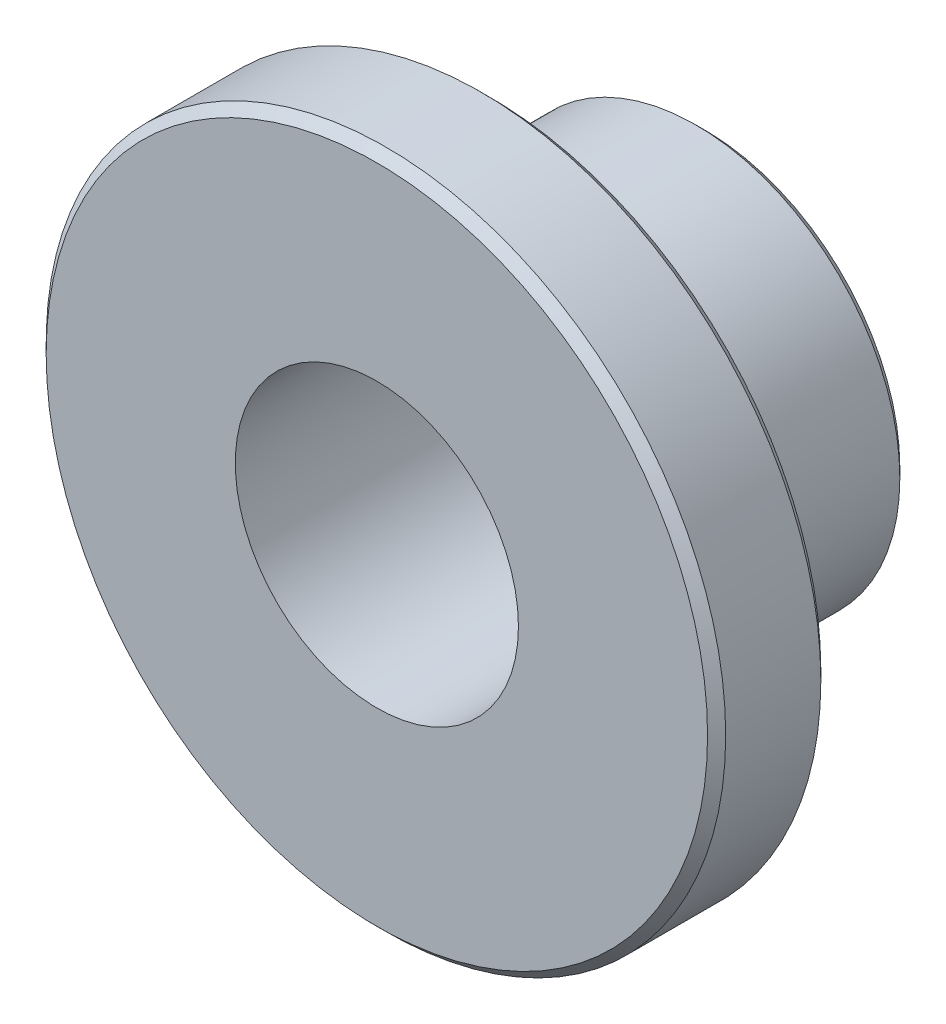
from build123d import *

# Parameters (mm, degrees)
SKETCH1_R           = 5.715
SKETCH1_R_2         = 3.96875
BOSS_EXTRUDE1_DEPTH = 4.6
SKETCH2_R           = 9.525
SKETCH2_R_2         = 5.715
BOSS_EXTRUDE2_DEPTH = 3.175
CHAMFER2_SIZE       = 0.254


with BuildPart() as part:
    # Sketch1 → Boss-Extrude1 (new body, symmetric)
    with BuildSketch(Plane.XY):
        Circle(SKETCH1_R)
        Circle(SKETCH1_R_2, mode=Mode.SUBTRACT)
    extrude(amount=BOSS_EXTRUDE1_DEPTH, both=True)

    # Sketch2 → Boss-Extrude2 (add)
    with BuildSketch(Plane.XY.offset(4.6)):
        Circle(SKETCH2_R)
        Circle(SKETCH2_R_2, mode=Mode.SUBTRACT)
    extrude(amount=-BOSS_EXTRUDE2_DEPTH)

    # Chamfer2
    chamfer2_edges = [part.edges().sort_by_distance(p)[0] for p in [
        (-9.525, 0, 1.425),
        (-9.525, 0, 4.6),
        (-5.715, 0, -4.6),
    ]]
    chamfer(chamfer2_edges, length=CHAMFER2_SIZE)


solid = part.part
